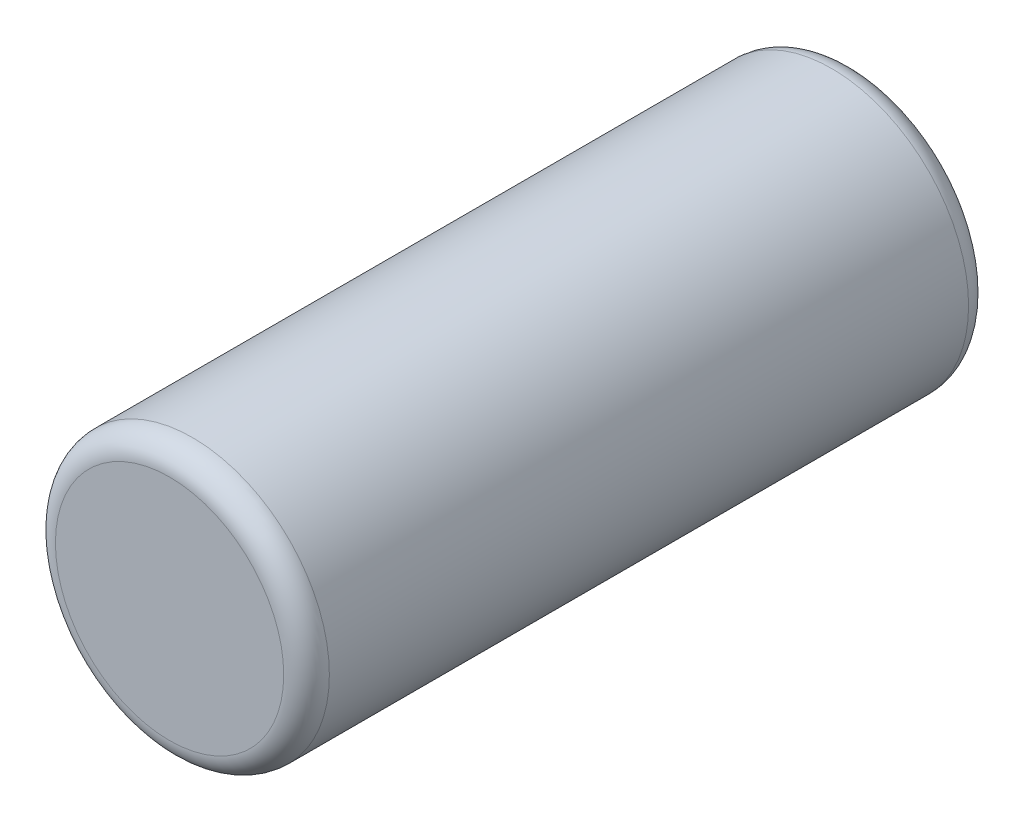
from build123d import *

# Parameters (mm, degrees)
ESQUISSE1_R        = 6
BOSS_EXTRU_1_DEPTH = 30
CONG_1_R           = 1


with BuildPart() as part:
    # Esquisse1 → Boss.-Extru.1 (new body)
    with BuildSketch(Plane.XY):
        Circle(ESQUISSE1_R)
    extrude(amount=BOSS_EXTRU_1_DEPTH)

    # Congé1
    cong_1_edges = [part.edges().sort_by_distance(p)[0] for p in [
        (-6, 0, 0),
        (-6, 0, 30),
    ]]
    fillet(cong_1_edges, radius=CONG_1_R)


solid = part.part
